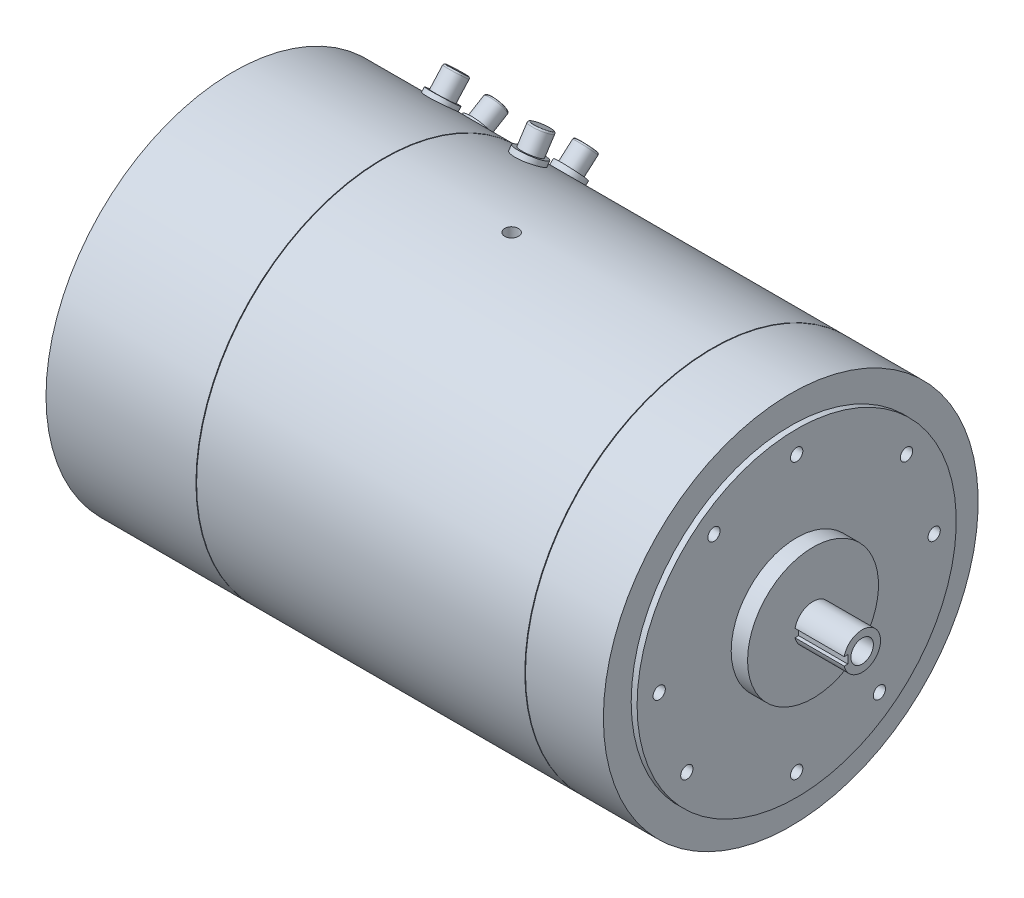
from build123d import *

# Parameters (mm, degrees)
SKETCH4_R                    = 4.7625
OUTPUT_MOUNT_HOLES_DEPTH     = 20.32
SKETCH5_R                    = 3.96875
AUX_OUTPUT_MOUNT_HOLES_DEPTH = 25.4
SKETCH10_R                   = 8.7376
PILOT_HOLE_DEPTH             = 19.05
F_5_16_18_TAPPED_HOLE4_D     = 6.5278
F_5_16_18_TAPPED_HOLE4_DEPTH = 32.4612
F_5_16_18_TAPPED_HOLE4_TIP   = 1.961148974
SKETCH13_W                   = 38.1
SKETCH13_H                   = 6.35
DRIVE_END_KEYWAY_DEPTH       = 19.05
F_1_4_20_TAPPED_HOLE1_D      = 5.1054
F_1_4_20_TAPPED_HOLE1_DEPTH  = 25.4
F_1_4_20_TAPPED_HOLE1_TIP    = 1.533816902
SKETCH16_W                   = 50.8
SKETCH16_H                   = 4.7752
CE_KEYWAY_DEPTH              = 19.05
SKETCH17_R                   = 8.255
A1_POST_DEPTH                = 25.4
SKETCH19_R                   = 11.43
A1_BASE_DEPTH                = 8.89
A1_FILLET_R                  = 1.27
A2_CONNECTOR_COUNT           = 2
A2_CONNECTOR_ANGLE           = 17
A1_FILLET_OF_A2_CONNECTOR_R  = 1.27
SKETCH20_R                   = 8.255
S1_POST_DEPTH                = 25.4
SKETCH21_R                   = 11.43
S1_BASE_DEPTH                = 9.525
S1_FILLET_R                  = 1.27
S2_CONNECTOR_COUNT           = 2
S2_CONNECTOR_ANGLE           = 16
S1_FILLET_OF_S2_CONNECTOR_R  = 1.27
LIFTING_HOLE_2_COUNT         = 2
LIFTING_HOLE_2_ANGLE         = 90


with BuildPart() as part:
    # Sketch2 → Revolve1 (revolve)
    with BuildSketch(Plane.XY, mode=Mode.PRIVATE) as revolve1_sk:
        Polygon((516.6614, 50.8), (516.6614, 14.2875), (554.7614, 14.2875), (554.7614, 0), (0, 0), (0, 11.1125), (57.404, 11.1125), (57.404, 36.83), (60.452, 36.83), (60.452, 101.6), (66.9036, 101.6), (66.9036, 145.415), (183.2356, 145.415), (183.2356, 142.875), (183.7436, 142.875), (183.7436, 145.415), (438.4294, 145.415), (438.4294, 142.875), (438.9374, 142.875), (438.9374, 145.415), (499.3894, 145.415), (499.3894, 123.825), (503.9614, 123.825), (503.9614, 50.8), align=None)
    revolve(revolve1_sk.sketch.rotate(Axis((-32.872294637, 0, 0), (1, 0, 0)), 90), axis=Axis((-32.872294637, 0, 0), (1, 0, 0)))  # turned: the seam where the file's is

    # Sketch4 → Output mount holes (cut)
    with BuildSketch(Plane(origin=(503.9614, 0, 0), x_dir=(0, 0, -1), z_dir=(1, 0, 0))):
        with Locations((106.68, 0)):
            Circle(SKETCH4_R)
        with Locations((85.198436212, 64.20162667)):
            Circle(SKETCH4_R)
        with Locations((0, -106.68)):
            Circle(SKETCH4_R)
        with Locations((64.20162667, -85.198436212)):
            Circle(SKETCH4_R)
        with Locations((-106.68, 0)):
            Circle(SKETCH4_R)
        with Locations((-85.198436212, -64.20162667)):
            Circle(SKETCH4_R)
        with Locations((0, 106.68)):
            Circle(SKETCH4_R)
        with Locations((-64.20162667, 85.198436212)):
            Circle(SKETCH4_R)
    extrude(amount=-OUTPUT_MOUNT_HOLES_DEPTH, mode=Mode.SUBTRACT)

    # Sketch5 → Aux output mount holes (cut)
    with BuildSketch(Plane.ZY.offset(-60.452)):
        with Locations((74.534847176, 15.84287084)):
            Circle(SKETCH5_R)
        with Locations((63.906697277, -41.501494468)):
            Circle(SKETCH5_R)
        with Locations((15.84287084, -74.534847176)):
            Circle(SKETCH5_R)
        with Locations((-41.501494468, -63.906697277)):
            Circle(SKETCH5_R)
        with Locations((-74.534847176, -15.84287084)):
            Circle(SKETCH5_R)
        with Locations((-63.906697277, 41.501494468)):
            Circle(SKETCH5_R)
        with Locations((-15.84287084, 74.534847176)):
            Circle(SKETCH5_R)
        with Locations((41.501494468, 63.906697277)):
            Circle(SKETCH5_R)
    extrude(amount=-AUX_OUTPUT_MOUNT_HOLES_DEPTH, mode=Mode.SUBTRACT)

    # Sketch10 → Pilot Hole (cut)
    with BuildSketch(Plane(origin=(554.7614, 0, 0), x_dir=(0, 0, -1), z_dir=(1, 0, 0))):
        Circle(SKETCH10_R)
    extrude(amount=-PILOT_HOLE_DEPTH, mode=Mode.SUBTRACT)

    # 5/16-18 Tapped Hole4
    with Locations(Plane(origin=(535.7114, 0, 0), x_dir=(0, 0, 1), z_dir=(1, 0, 0))):
        with Locations((0, 0)):
            Hole(F_5_16_18_TAPPED_HOLE4_D / 2, depth=F_5_16_18_TAPPED_HOLE4_DEPTH)
            with Locations((0, 0, -(F_5_16_18_TAPPED_HOLE4_DEPTH + F_5_16_18_TAPPED_HOLE4_TIP / 2))):  # 118° drill point
                Cone(0, F_5_16_18_TAPPED_HOLE4_D / 2, F_5_16_18_TAPPED_HOLE4_TIP, mode=Mode.SUBTRACT)

    # Sketch13 → Drive End Keyway (cut)
    with BuildSketch(Plane.XY.offset(11.1125)):
        with Locations((535.7114, 0)):
            Rectangle(SKETCH13_W, SKETCH13_H)
    extrude(amount=DRIVE_END_KEYWAY_DEPTH, mode=Mode.SUBTRACT)

    # 1/4-20 Tapped Hole1
    with Locations(Plane.ZY):
        with Locations((0, 0)):
            Hole(F_1_4_20_TAPPED_HOLE1_D / 2, depth=F_1_4_20_TAPPED_HOLE1_DEPTH)
            with Locations((0, 0, -(F_1_4_20_TAPPED_HOLE1_DEPTH + F_1_4_20_TAPPED_HOLE1_TIP / 2))):  # 118° drill point
                Cone(0, F_1_4_20_TAPPED_HOLE1_D / 2, F_1_4_20_TAPPED_HOLE1_TIP, mode=Mode.SUBTRACT)

    # Sketch16 → CE Keyway (cut)
    with BuildSketch(Plane.XY.offset(8.4709)):
        with Locations((25.4, 0)):
            Rectangle(SKETCH16_W, SKETCH16_H)
    extrude(amount=CE_KEYWAY_DEPTH, mode=Mode.SUBTRACT)

    # Sketch17 → A1 Post (add)
    with BuildSketch(Plane(origin=(0, 103.817332119, -93.477545708), x_dir=(-1, 0, 0), z_dir=(0, -0.743144825, 0.669130606))):
        with Locations(Location((-129.8956, 0, 0), (0, 0, 90))):  # turned: the seam where the file's is
            Circle(SKETCH17_R)
    a1_post = extrude(amount=-A1_POST_DEPTH)

    # Sketch19 → A1 Base (add)
    with BuildSketch(Plane(origin=(0, 103.817332119, -93.477545708), x_dir=(-1, 0, 0), z_dir=(0, -0.743144825, 0.669130606))):
        with Locations(Location((-129.8956, 0, 0), (0, 0, 90))):  # turned: the seam where the file's is
            Circle(SKETCH19_R)
    a1_base = extrude(amount=-A1_BASE_DEPTH)

    # A1 Fillet
    a1_fillet_edges = [part.edges().sort_by_distance(p)[0] for p in [
        (129.8956, 128.216883842, -104.338802576),
    ]]
    fillet(a1_fillet_edges, radius=A1_FILLET_R)

    # A2 Connector: A1 Post, A1 Base ×2 about axis
    a2_connector_axis = Axis((-32.872294637, 0, 0), (-1, 0, 0))
    add([a1_post.rotate(a2_connector_axis, i * A2_CONNECTOR_ANGLE / (A2_CONNECTOR_COUNT - 1)) for i in range(1, A2_CONNECTOR_COUNT)])
    add([a1_base.rotate(a2_connector_axis, i * A2_CONNECTOR_ANGLE / (A2_CONNECTOR_COUNT - 1)) for i in range(1, A2_CONNECTOR_COUNT)])

    # A1 Fillet of A2 Connector
    a1_fillet_of_a2_connector_edges = [part.edges().sort_by_distance(p)[0] for p in [
        (129.8956, 92.108702235, -137.266682038),
    ]]
    fillet(a1_fillet_of_a2_connector_edges, radius=A1_FILLET_OF_A2_CONNECTOR_R)

    # Sketch20 → S1 Post (add)
    with BuildSketch(Plane(origin=(0, 91.65144635, -105.432928357), x_dir=(1, 0, 0), z_dir=(0, -0.656059029, 0.75470958))):
        with Locations(Location((216.2556, 0, 0), (0, 0, 270))):  # turned: the seam where the file's is
            Circle(SKETCH20_R)
    s1_post = extrude(amount=-S1_POST_DEPTH)

    # Sketch21 → S1 Base (add)
    with BuildSketch(Plane(origin=(0, 91.65144635, -105.432928357), x_dir=(1, 0, 0), z_dir=(0, -0.656059029, 0.75470958))):
        with Locations(Location((216.2556, 0, 0), (0, 0, 270))):  # turned: the seam where the file's is
            Circle(SKETCH21_R)
    s1_base = extrude(amount=-S1_BASE_DEPTH)

    # S1 Fillet
    s1_fillet_edges = [part.edges().sort_by_distance(p)[0] for p in [
        (216.2556, 114.545473271, -119.18678441),
    ]]
    fillet(s1_fillet_edges, radius=S1_FILLET_R)

    # S2 Connector: S1 Post, S1 Base ×2 about axis
    s2_connector_axis = Axis((-32.872294637, 0, 0), (1, 0, 0))
    add([s1_post.rotate(s2_connector_axis, i * S2_CONNECTOR_ANGLE / (S2_CONNECTOR_COUNT - 1)) for i in range(1, S2_CONNECTOR_COUNT)])
    add([s1_base.rotate(s2_connector_axis, i * S2_CONNECTOR_ANGLE / (S2_CONNECTOR_COUNT - 1)) for i in range(1, S2_CONNECTOR_COUNT)])

    # S1 Fillet of S2 Connector
    s1_fillet_of_s2_connector_edges = [part.edges().sort_by_distance(p)[0] for p in [
        (216.2556, 142.960506002, -82.996679143),
    ]]
    fillet(s1_fillet_of_s2_connector_edges, radius=S1_FILLET_OF_S2_CONNECTOR_R)

    # Sketch25 → Lifting Hole (revolve, cut)
    with BuildSketch(Plane(origin=(282.8036, 145.415, 0), x_dir=(0, 0, 1), z_dir=(1, 0, 0))):
        Polygon((0, 0), (0, 38.398489309), (5.35813, 35.179), (5.35813, 0), align=None)
    lifting_hole = revolve(axis=Axis((282.8036, 151.765, 0), (0, -1, 0)), mode=Mode.SUBTRACT)

    # Lifting Hole 2: Lifting Hole ×2 about axis
    lifting_hole_2_axis = Axis((-32.872294637, 0, 0), (-1, 0, 0))
    for i in range(1, LIFTING_HOLE_2_COUNT):
        add(lifting_hole.rotate(lifting_hole_2_axis, i * LIFTING_HOLE_2_ANGLE / (LIFTING_HOLE_2_COUNT - 1)), mode=Mode.SUBTRACT)


solid = part.part
